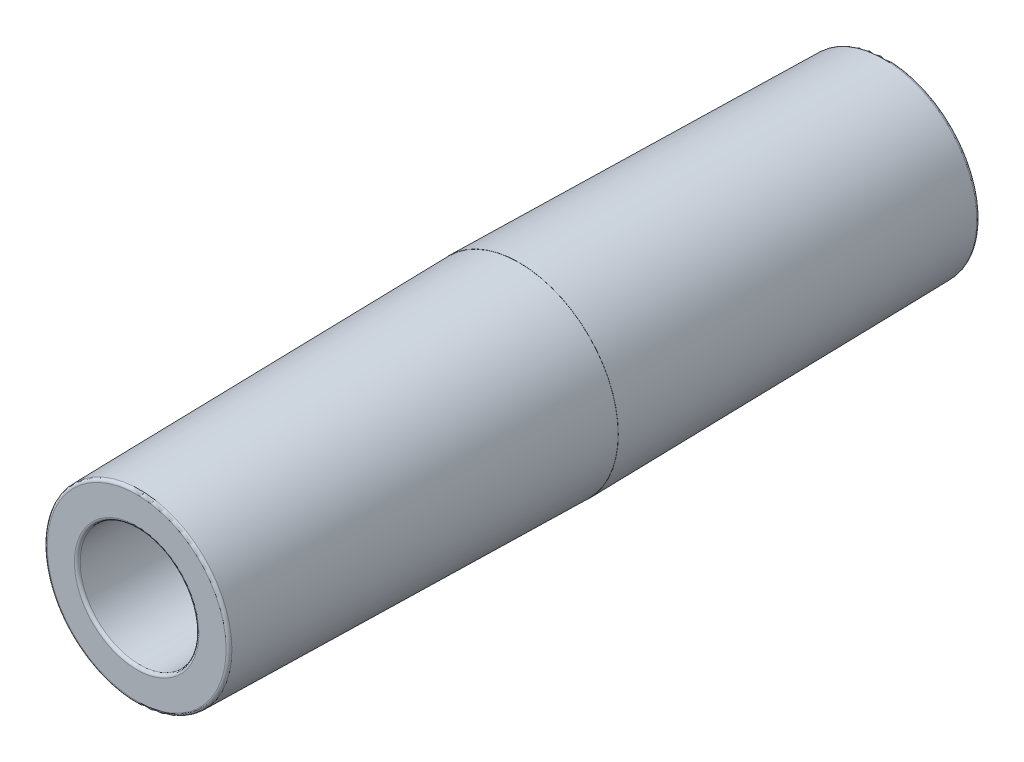
from build123d import *

# Parameters (mm, degrees)
FILLET1_R = 0.254


with BuildPart() as part:
    # Sketch1 → Revolve1 (revolve)
    with BuildSketch(Plane(origin=(0, 0, 0), x_dir=(1, 0, 0), z_dir=(0, 1, 0))):
        Polygon((5.126280771, 31.75), (4.8514, 0), (4.8387, 0), (5.124663893, -33.02), (7.970733756, -33.02), (8.5471, 0), (8.5598, 0), (8.005601689, 31.75), align=None)
    revolve(axis=Axis((0, 0, -31.75297092), (0, 0, 1)))

    # Fillet1
    fillet1_edges = [part.edges().sort_by_distance(p)[0] for p in [
        (-8.005601689, 0, -31.75),
        (-7.970733756, 0, 33.02),
        (-5.124663893, 0, 33.02),
        (-5.126280771, 0, -31.75),
    ]]
    fillet(fillet1_edges, radius=FILLET1_R)


solid = part.part
